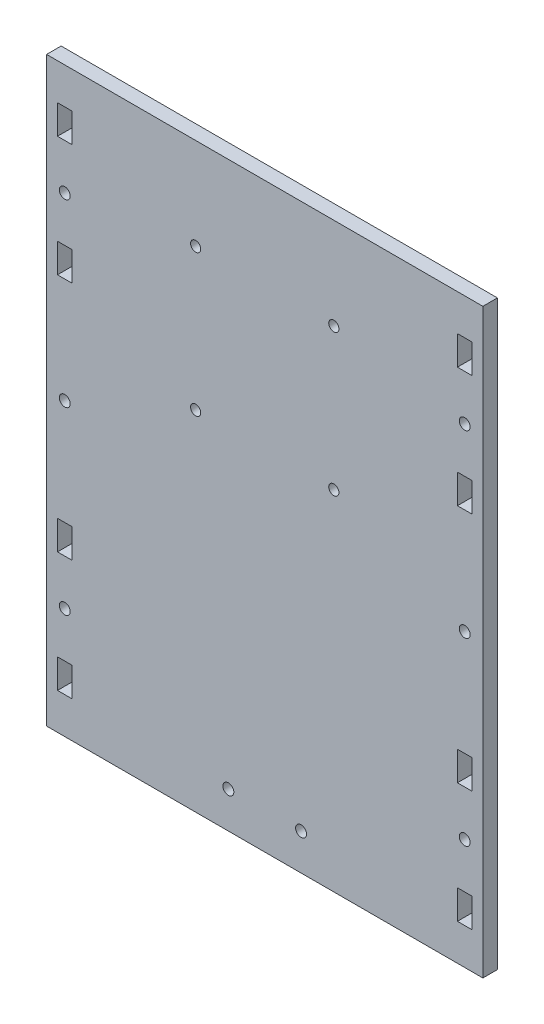
from build123d import *

# Parameters (mm, degrees)
SKETCH1_W           = 4
SKETCH1_H           = 8
SKETCH1_R           = 1.5
SKETCH1_R_2         = 1.4
BOSS_EXTRUDE2_DEPTH = 4


with BuildPart() as part:
    # Sketch1 → Boss-Extrude2 (new body)
    with BuildSketch(Plane.XY):
        Polygon((-10, 80), (-60, 80), (-60, -80), (60, -80), (60, 80), (10, 80), align=None)
        with Locations((-55, -66)):
            Rectangle(SKETCH1_W, SKETCH1_H, mode=Mode.SUBTRACT)
        with Locations((-55, -49.5)):
            Circle(SKETCH1_R, mode=Mode.SUBTRACT)
        with Locations((-10, -70)):
            Circle(SKETCH1_R, mode=Mode.SUBTRACT)
        with Locations((-55, -33)):
            Rectangle(SKETCH1_W, SKETCH1_H, mode=Mode.SUBTRACT)
        with Locations((10, -70)):
            Circle(SKETCH1_R, mode=Mode.SUBTRACT)
        with Locations((55, -66)):
            Rectangle(SKETCH1_W, SKETCH1_H, mode=Mode.SUBTRACT)
        with Locations((55, -49.5)):
            Circle(SKETCH1_R, mode=Mode.SUBTRACT)
        with Locations((55, -33)):
            Rectangle(SKETCH1_W, SKETCH1_H, mode=Mode.SUBTRACT)
        with Locations((-55, 0)):
            Circle(SKETCH1_R, mode=Mode.SUBTRACT)
        with Locations((-55, 33)):
            Rectangle(SKETCH1_W, SKETCH1_H, mode=Mode.SUBTRACT)
        with Locations((-19, 15.8)):
            Circle(SKETCH1_R_2, mode=Mode.SUBTRACT)
        with Locations((-55, 49.5)):
            Circle(SKETCH1_R, mode=Mode.SUBTRACT)
        with Locations((-55, 66)):
            Rectangle(SKETCH1_W, SKETCH1_H, mode=Mode.SUBTRACT)
        with Locations((-19, 54.8)):
            Circle(SKETCH1_R_2, mode=Mode.SUBTRACT)
        with Locations((19, 15.8)):
            Circle(SKETCH1_R_2, mode=Mode.SUBTRACT)
        with Locations((55, 0)):
            Circle(SKETCH1_R, mode=Mode.SUBTRACT)
        with Locations((55, 33)):
            Rectangle(SKETCH1_W, SKETCH1_H, mode=Mode.SUBTRACT)
        with Locations((19, 54.8)):
            Circle(SKETCH1_R_2, mode=Mode.SUBTRACT)
        with Locations((55, 49.5)):
            Circle(SKETCH1_R, mode=Mode.SUBTRACT)
        with Locations((55, 66)):
            Rectangle(SKETCH1_W, SKETCH1_H, mode=Mode.SUBTRACT)
    extrude(amount=BOSS_EXTRUDE2_DEPTH)


solid = part.part
